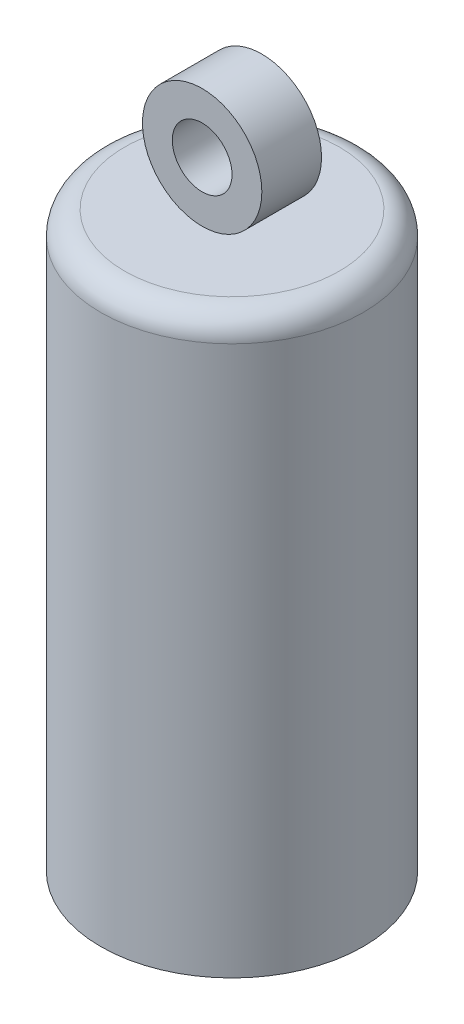
from build123d import *

# Parameters (mm, degrees)
SKETCH1_R           = 5.5
BOSS_EXTRUDE1_DEPTH = 1.5
SKETCH2_R           = 2.5
SKETCH2_R_2         = 1.25
BOSS_EXTRUDE2_DEPTH = 1.25
FILLET1_R           = 1
SKETCH3_R           = 5.5
SKETCH3_R_2         = 5.35
BOSS_EXTRUDE3_DEPTH = 22.5
SKETCH4_R           = 2.75
SKETCH4_R_2         = 2.6
BOSS_EXTRUDE4_DEPTH = 22.5


with BuildPart() as part:
    # Sketch1 → Boss-Extrude1 (new body)
    with BuildSketch(Plane(origin=(0, 0, 0), x_dir=(1, 0, 0), z_dir=(0, 1, 0))):
        Circle(SKETCH1_R)
    extrude(amount=BOSS_EXTRUDE1_DEPTH)

    # Fillet1
    fillet1_edges = [part.edges().sort_by_distance(p)[0] for p in [
        (-5.5, 1.5, 0),
    ]]
    fillet(fillet1_edges, radius=FILLET1_R)

    # Sketch3 → Boss-Extrude3 (add)
    with BuildSketch(Plane.XZ):
        Circle(SKETCH3_R)
        Circle(SKETCH3_R_2, mode=Mode.SUBTRACT)
    extrude(amount=BOSS_EXTRUDE3_DEPTH)

    # Sketch4 → Boss-Extrude4 (add)
    with BuildSketch(Plane.XZ):
        Circle(SKETCH4_R)
        Circle(SKETCH4_R_2, mode=Mode.SUBTRACT)
    extrude(amount=BOSS_EXTRUDE4_DEPTH)


with BuildPart() as body_2:
    # Sketch2 → Boss-Extrude2 (new body, symmetric)
    with BuildSketch(Plane.XY):
        with Locations((0, 4)):
            Circle(SKETCH2_R)
        with Locations((0, 4)):
            Circle(SKETCH2_R_2, mode=Mode.SUBTRACT)
    extrude(amount=BOSS_EXTRUDE2_DEPTH, both=True)


solid = Compound([part.part, body_2.part])
